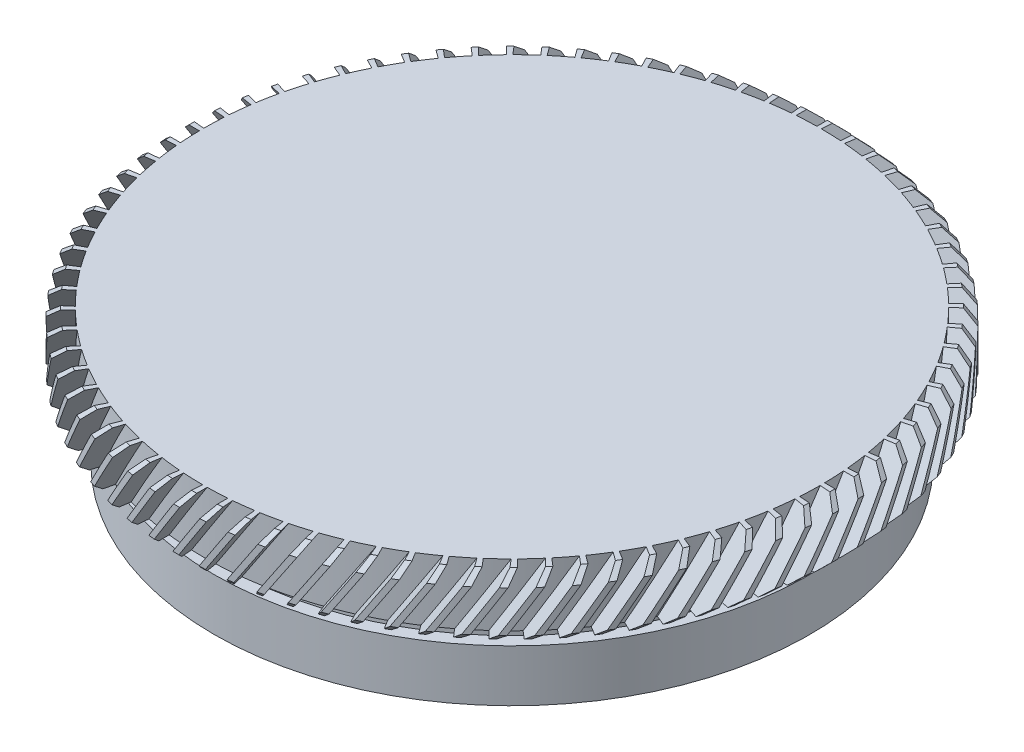
from build123d import *

# Parameters (mm, degrees)
CHAMFER_1_SIZE           = 0.5
CUT_EXTRUDE_1_REACH      = 63.343
CUT_EXTRUDE_1_END_RADIUS = 14.875
CUT_EXTRUDE_START        = 30
PATTERN_CIRCULAR_2_COUNT = 80


with BuildPart() as part:
    # 草图1 → 旋转2 (revolve)
    with BuildSketch(Plane.XY, mode=Mode.PRIVATE) as revolve_2_sk:
        Polygon((0, 21.871257405), (15.875, 21.871257405), (15.875, 18.871257405), (13.75, 18.871257405), (13.75, 17.871257405), (14.35, 17.871257405), (14.35, 15.371257405), (12.5, 15.371257405), (12.5, 18.871257405), (0, 18.871257405), align=None)
    revolve(revolve_2_sk.sketch.rotate(Axis((0, 66.628762136, 0), (0, -1, 0)), 90), axis=Axis((0, 66.628762136, 0), (0, -1, 0)))

    # 倒角1
    chamfer_1_edges = [part.edges().sort_by_distance(p)[0] for p in [
        (0, 21.871257405, -15.875),
        (0, 18.871257405, -15.875),
    ]]
    chamfer(chamfer_1_edges, length=CHAMFER_1_SIZE)

    # 切除-拉伸1: up to this cylinder (the profile starts outside it)
    cut_extrude_1_end = Plane(origin=(0, 18.072086, 0), z_dir=(0, 1, 0)) * Cylinder(CUT_EXTRUDE_1_END_RADIUS, 157.436, mode=Mode.PRIVATE)
    # 草图2 → 切除-拉伸1 (cut, up to the surface)
    with BuildSketch(Plane.XY.offset(CUT_EXTRUDE_START), mode=Mode.PRIVATE) as cut_extrude_1_sk1:
        Polygon((1.108168834, 23.303253722), (-5.339513804, 13.273525174), (-4.666571024, 12.840919101), (1.781111614, 22.870647649), align=None)
    cut_extrude_1_tool1 = extrude(cut_extrude_1_sk1.sketch, amount=-CUT_EXTRUDE_1_REACH, mode=Mode.PRIVATE) - cut_extrude_1_end
    cut_extrude_1 = cut_extrude_1_tool1.solids().sort_by_distance((-1.779201, 18.072086, 30))[0]
    add(cut_extrude_1, mode=Mode.SUBTRACT)

    # 阵列(圆周)2: 切除-拉伸1 ×80 about axis
    pattern_circular_2_axis = Axis((0, 0, 0), (0, 1, 0))
    for i in range(1, PATTERN_CIRCULAR_2_COUNT):
        add(cut_extrude_1.rotate(pattern_circular_2_axis, i * 360 / PATTERN_CIRCULAR_2_COUNT), mode=Mode.SUBTRACT)


solid = part.part
